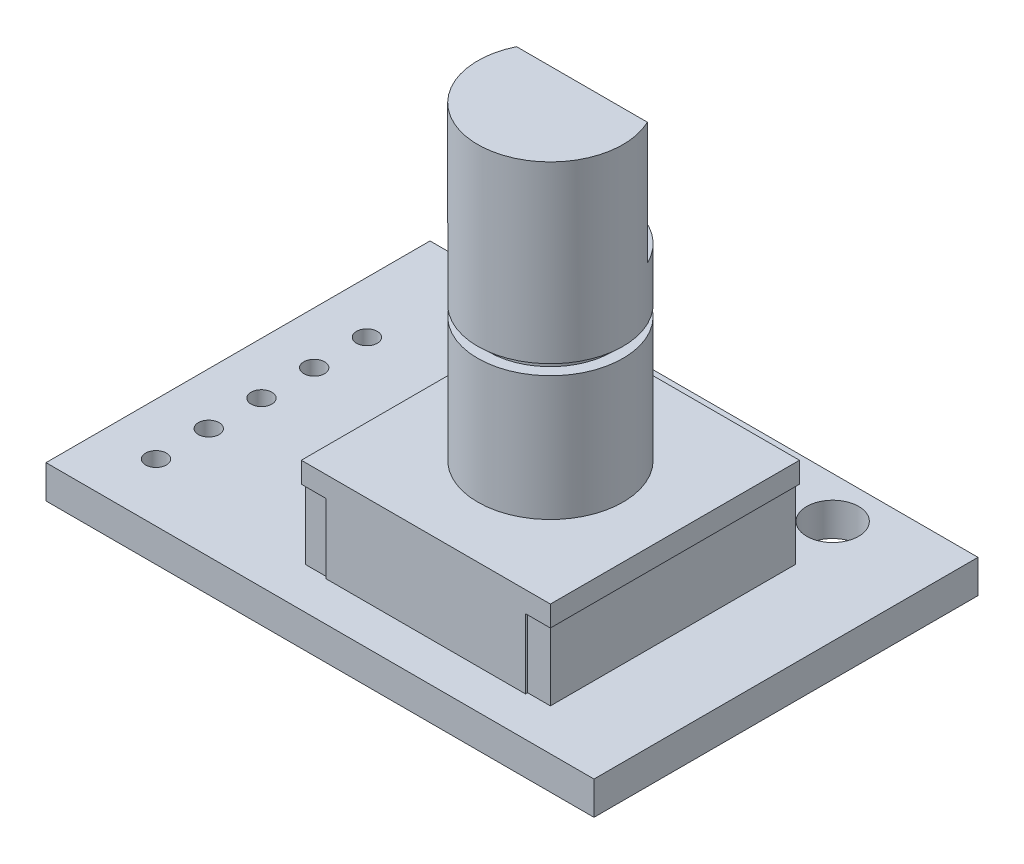
from build123d import *

# Parameters (mm, degrees)
SKETCH1_W           = 26.4
SKETCH1_H           = 18.5
SKETCH1_R           = 1.25
SKETCH1_R_2         = 0.5
BOSS_EXTRUDE1_DEPTH = 1.6
SKETCH2_W           = 12
SKETCH2_H           = 12
BOSS_EXTRUDE2_DEPTH = 4.35
CUT_EXTRUDE1_DEPTH  = 3.35
SKETCH4_R           = 3.5
BOSS_EXTRUDE3_DEPTH = 6
SKETCH5_R           = 2.967094381
BOSS_EXTRUDE4_DEPTH = 0.5
SKETCH6_R           = 3.5
BOSS_EXTRUDE5_DEPTH = 2.54
BOSS_EXTRUDE6_DEPTH = 5.88


with BuildPart() as part:
    # Sketch1 → Boss-Extrude1 (new body)
    with BuildSketch(Plane(origin=(0, 0, 0), x_dir=(1, 0, 0), z_dir=(0, 1, 0))):
        Rectangle(SKETCH1_W, SKETCH1_H)
        with Locations((-5.8, 7.25)):
            Circle(SKETCH1_R, mode=Mode.SUBTRACT)
        with Locations((8.2, 7.25)):
            Circle(SKETCH1_R, mode=Mode.SUBTRACT)
        with Locations((-10.7, -6.45)):
            Circle(SKETCH1_R_2, mode=Mode.SUBTRACT)
        with Locations((-10.7, -3.91)):
            Circle(SKETCH1_R_2, mode=Mode.SUBTRACT)
        with Locations((-10.7, -1.37)):
            Circle(SKETCH1_R_2, mode=Mode.SUBTRACT)
        with Locations((-10.7, 1.17)):
            Circle(SKETCH1_R_2, mode=Mode.SUBTRACT)
        with Locations((-10.7, 3.71)):
            Circle(SKETCH1_R_2, mode=Mode.SUBTRACT)
    extrude(amount=BOSS_EXTRUDE1_DEPTH)

    # Sketch2 → Boss-Extrude2 (add)
    with BuildSketch(Plane(origin=(0, 1.6, 0), x_dir=(1, 0, 0), z_dir=(0, 1, 0))):
        with Locations((3.2, -1.35)):
            Rectangle(SKETCH2_W, SKETCH2_H)
    extrude(amount=BOSS_EXTRUDE2_DEPTH)

    # Sketch3 → Cut-Extrude1 (cut)
    with BuildSketch(Plane(origin=(0, 1.6, 0), x_dir=(1, 0, 0), z_dir=(0, 1, 0))):
        Polygon((-1.6, 4.65), (-2.8, 4.65), (-2.8, -7.35), (-1.6, -7.35), (-1.6, -7.25), (-2.7, -7.25), (-2.7, 4.55), (-1.6, 4.55), align=None)
        Polygon((8, -7.35), (8, -7.25), (9.1, -7.25), (9.1, 4.55), (8, 4.55), (8, 4.65), (9.2, 4.65), (9.2, -7.35), align=None)
    extrude(amount=CUT_EXTRUDE1_DEPTH, mode=Mode.SUBTRACT)

    # Sketch4 → Boss-Extrude3 (add)
    with BuildSketch(Plane(origin=(0, 5.95, 0), x_dir=(1, 0, 0), z_dir=(0, 1, 0))):
        with Locations((3.2, -1.35)):
            Circle(SKETCH4_R)
    extrude(amount=BOSS_EXTRUDE3_DEPTH)

    # Sketch5 → Boss-Extrude4 (add)
    with BuildSketch(Plane(origin=(0, 11.95, 0), x_dir=(1, 0, 0), z_dir=(0, 1, 0))):
        with Locations((3.2, -1.35)):
            Circle(SKETCH5_R)
    extrude(amount=BOSS_EXTRUDE4_DEPTH)

    # Sketch6 → Boss-Extrude5 (add)
    with BuildSketch(Plane(origin=(0, 12.45, 0), x_dir=(1, 0, 0), z_dir=(0, 1, 0))):
        with Locations((3.2, -1.35)):
            Circle(SKETCH6_R)
    extrude(amount=BOSS_EXTRUDE5_DEPTH)

    # Sketch7 → Boss-Extrude6 (add)
    with BuildSketch(Plane(origin=(0, 14.99, 0), x_dir=(1, 0, 0), z_dir=(0, 1, 0))):
        with BuildLine():
            Line((0.047286883, 0.17), (6.352713117, 0.17))
            ThreePointArc((6.352713117, 0.17), (3.2, -4.85), (0.047286883, 0.17))
        make_face()
    extrude(amount=BOSS_EXTRUDE6_DEPTH)


solid = part.part
